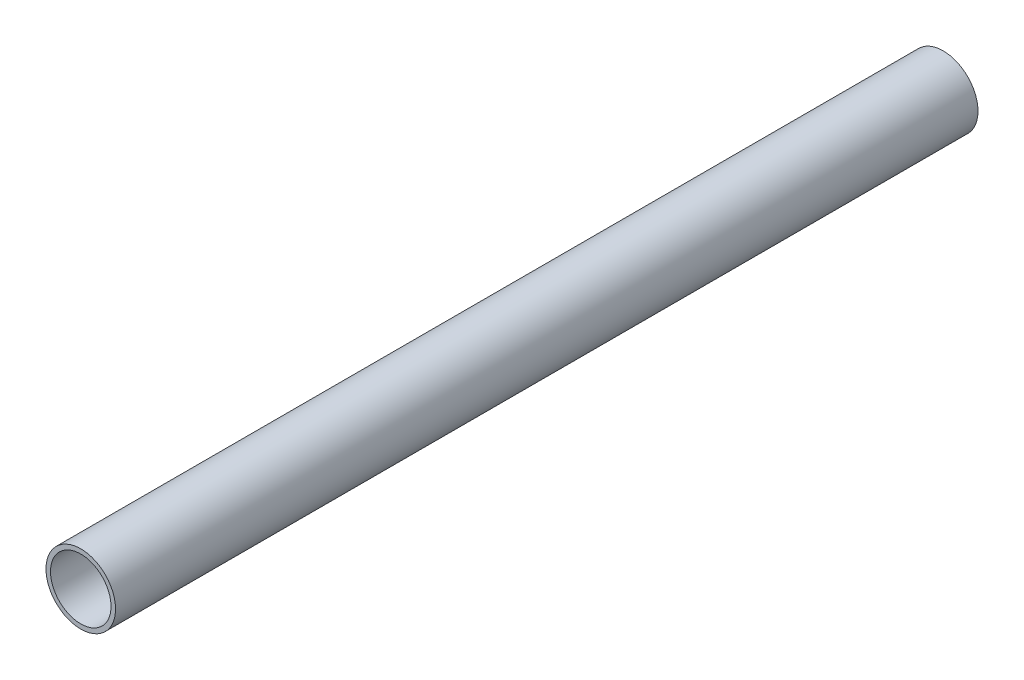
from build123d import *

# Parameters (mm, degrees)
SKETCH1_R           = 30.1625
SKETCH1_R_2         = 26.2509
BOSS_EXTRUDE1_DEPTH = 747.90315


with BuildPart() as part:
    # Sketch1 → Boss-Extrude1 (new body)
    with BuildSketch(Plane.XY):
        Circle(SKETCH1_R)
        Circle(SKETCH1_R_2, mode=Mode.SUBTRACT)
    extrude(amount=BOSS_EXTRUDE1_DEPTH)


solid = part.part
